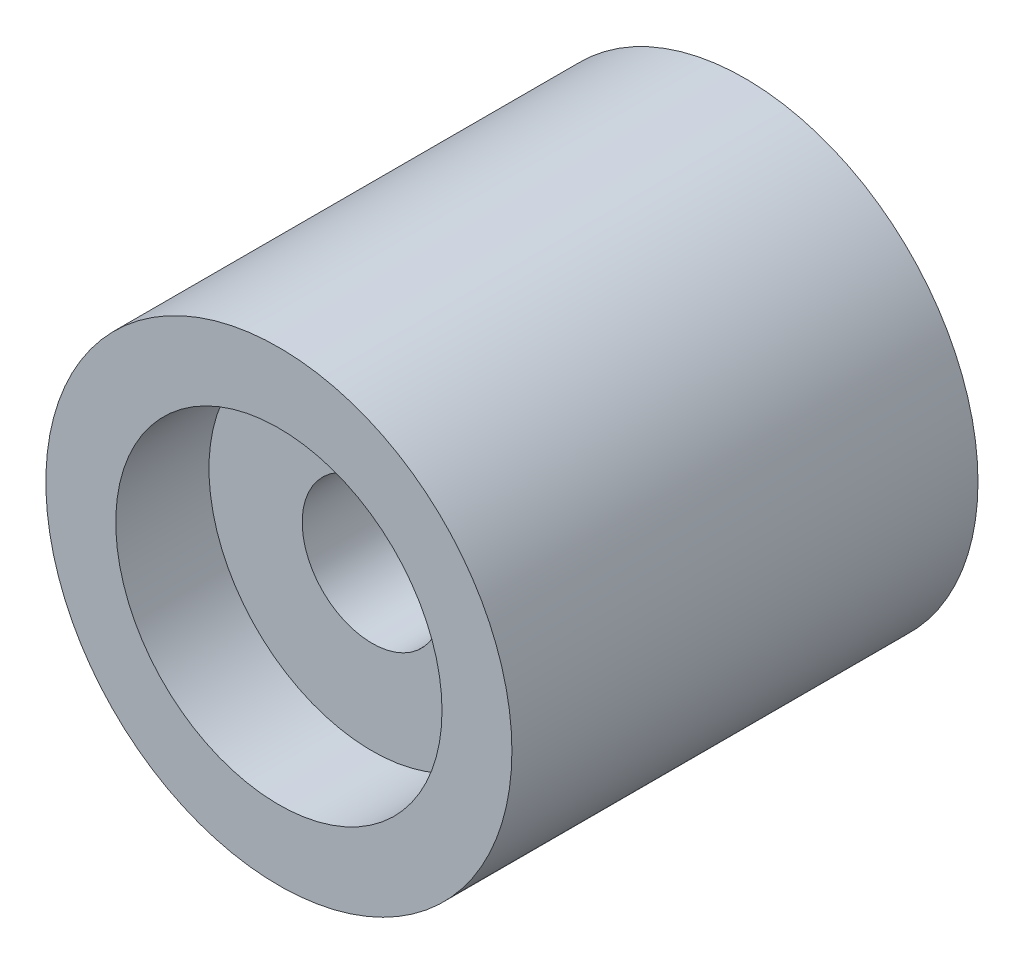
from build123d import *

# Parameters (mm, degrees)
SKETCH1_R           = 5
BOSS_EXTRUDE1_DEPTH = 10
SKETCH2_R           = 3.5
CUT_EXTRUDE1_DEPTH  = 2
SKETCH3_R           = 3.5
CUT_EXTRUDE2_DEPTH  = 2
SKETCH4_R           = 1.5
CUT_EXTRUDE3_DEPTH  = 12


with BuildPart() as part:
    # Sketch1 → Boss-Extrude1 (new body)
    with BuildSketch(Plane.XY):
        Circle(SKETCH1_R)
    extrude(amount=BOSS_EXTRUDE1_DEPTH)

    # Sketch2 → Cut-Extrude1 (cut)
    with BuildSketch(Plane.XY):
        Circle(SKETCH2_R)
    extrude(amount=CUT_EXTRUDE1_DEPTH, mode=Mode.SUBTRACT)

    # Sketch3 → Cut-Extrude2 (cut)
    with BuildSketch(Plane.XY.offset(10)):
        Circle(SKETCH3_R)
    extrude(amount=-CUT_EXTRUDE2_DEPTH, mode=Mode.SUBTRACT)

    # Sketch4 → Cut-Extrude3 (cut)
    with BuildSketch(Plane.XY.offset(10)):
        Circle(SKETCH4_R)
    extrude(amount=-CUT_EXTRUDE3_DEPTH, mode=Mode.SUBTRACT)


solid = part.part
